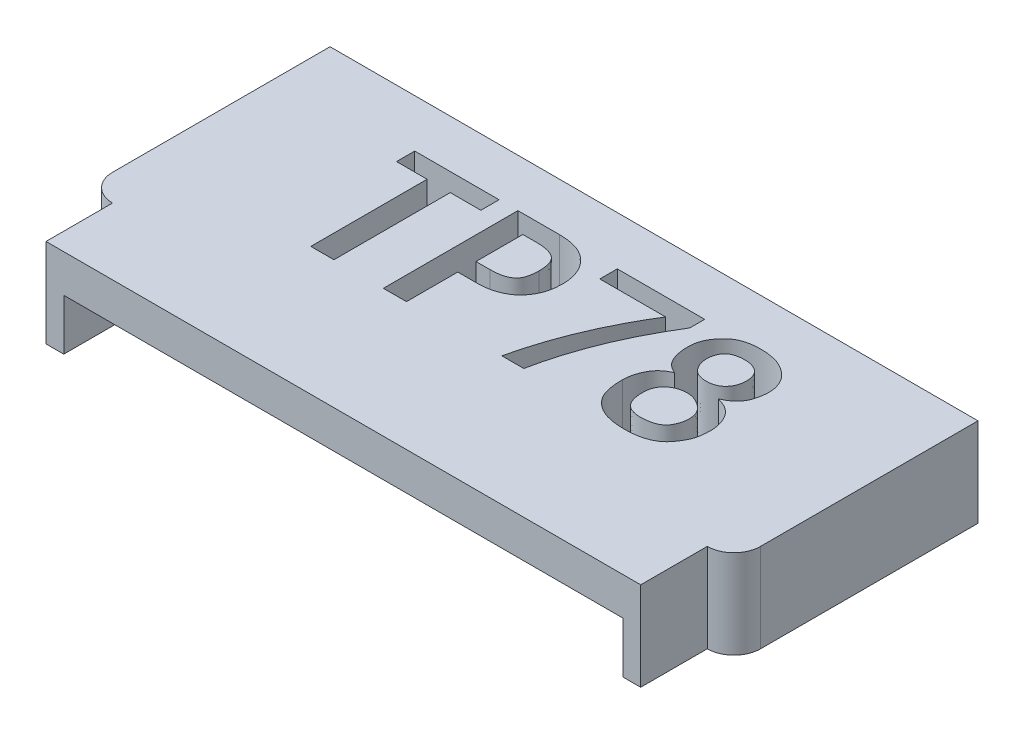
from build123d import *

# Parameters (mm, degrees)
EXTRUDE_1_DEPTH     = 2
SKETCH_2_W          = 13.4
SKETCH_2_H          = 0.85
EXTRUDE_2_DEPTH     = 1.5
SKETCH_4_W          = 0.4
SKETCH_4_H          = 1.5
EXTRUDE_3_DEPTH     = 1.15
CUT_EXTRUDE_2_DEPTH = 1.9


with BuildPart() as part:
    # 草图1 → 凸台-拉伸1 (new body)
    with BuildSketch(Plane(origin=(0, 0, 0), x_dir=(1, 0, 0), z_dir=(0, 1, 0))):
        with BuildLine():
            Line((0, 0), (14.6, 0))
            Line((14.6, 0), (14.6, -4.9))
            ThreePointArc((14.6, -4.9), (14.424264069, -5.324264069), (14, -5.5))
            Line((14, -5.5), (0.6, -5.5))
            ThreePointArc((0.6, -5.5), (0.175735931, -5.324264069), (0, -4.9))
            Line((0, -4.9), (0, 0))
        make_face()
    extrude(amount=EXTRUDE_1_DEPTH)

    # 草图2 → 凸台-拉伸2 (add)
    with BuildSketch(Plane.XY.offset(5.5)):
        with Locations((7.3, 1.575)):
            Rectangle(SKETCH_2_W, SKETCH_2_H)
    extrude(amount=EXTRUDE_2_DEPTH)

    # 草图4 → 凸台-拉伸3 (add)
    with BuildSketch(Plane.XZ.offset(-1.15)):
        with Locations((13.8, 6.25)):
            Rectangle(SKETCH_4_W, SKETCH_4_H)
        with Locations((0.8, 6.25)):
            Rectangle(SKETCH_4_W, SKETCH_4_H)
    extrude(amount=EXTRUDE_3_DEPTH)

    # 草图5 → 切除-拉伸2 (cut)
    with BuildSketch(Plane(origin=(0, 2, 0), x_dir=(1, 0, 0), z_dir=(0, 1, 0))):
        Polygon((4.890749255, -1.492372346), (4.200990709, -1.492372346), (4.200990709, -4.113454824), (3.679767505, -4.113454824), (3.679767505, -1.492372346), (2.990008958, -1.492372346), (2.990008958, -1.081770796), (4.890749255, -1.081770796), align=None)
        with BuildLine():
            add(Edge.make_bspline(
                [(7.250244058, -2.020102706), (7.249588052, -2.054198925), (7.248300741, -2.12110749), (7.235435369, -2.218842293), (7.215685623, -2.311802101), (7.18683198, -2.399386965), (7.150113887, -2.481946077), (7.105912509, -2.559909986), (7.052578704, -2.6325659), (6.991611486, -2.700022576), (6.923466067, -2.761344443), (6.847973696, -2.814568737), (6.765216911, -2.858896104), (6.67571216, -2.895202208), (6.579674756, -2.924025827), (6.476760526, -2.943758576), (6.367328834, -2.956533615), (6.291994599, -2.957790055), (6.253347743, -2.958434616)],
                knots=[0, 0, 0, 0, 0.000102237, 0.000200624, 0.000295202, 0.000386978, 0.000476702, 0.000565888, 0.000655304, 0.000746525, 0.000838229, 0.000929761, 0.001022929, 0.001119237, 0.001219085, 0.00132322, 0.001433237, 0.001549131, 0.001549131, 0.001549131, 0.001549131], degree=3))
            Line((6.253347743, -2.958434616), (5.836239037, -2.958434616))
            Line((5.836239037, -2.958434616), (5.836239037, -4.113454824))
            Line((5.836239037, -4.113454824), (5.315015833, -4.113454824))
            Line((5.315015833, -4.113454824), (5.315015833, -1.081770796))
            Line((5.315015833, -1.081770796), (6.253347743, -1.081770796))
            add(Edge.make_bspline(
                [(6.253347743, -1.081770796), (6.291994529, -1.082415664), (6.367328626, -1.083672703), (6.476761295, -1.0964435), (6.579672089, -1.116191167), (6.675528981, -1.1449048), (6.764910531, -1.181332217), (6.847145559, -1.226391406), (6.922843349, -1.279466128), (6.99094071, -1.340852959), (7.051979576, -1.408258454), (7.105143306, -1.481139333), (7.150246789, -1.558709082), (7.186782006, -1.641497342), (7.215704849, -1.729045512), (7.235364597, -1.821807991), (7.248341807, -1.919308354), (7.249600543, -1.986004845), (7.250244058, -2.020102706)],
                knots=[0, 0, 0, 0, 0.000115893, 0.00022591, 0.000330045, 0.000429893, 0.000525599, 0.000619079, 0.00071061, 0.000802315, 0.000893536, 0.000982952, 0.001072462, 0.001162186, 0.001253962, 0.00134854, 0.001446282, 0.001548518, 0.001548518, 0.001548518, 0.001548518], degree=3))
        make_face()
        with BuildLine():
            add(Edge.make_bspline(
                [(6.729020854, -2.020102706), (6.728799011, -1.995570897), (6.728371926, -1.948343196), (6.720895699, -1.880729094), (6.709963299, -1.819160596), (6.695441479, -1.763282456), (6.675317679, -1.713608058), (6.650512993, -1.670300322), (6.621598057, -1.632972382), (6.587606561, -1.602043947), (6.549275727, -1.575578765), (6.505772746, -1.553916764), (6.458364391, -1.534085644), (6.405785746, -1.518532418), (6.348453702, -1.507162326), (6.286515449, -1.498785023), (6.219816633, -1.493529018), (6.173753603, -1.492767145), (6.149883961, -1.492372346)],
                knots=[0, 0, 0, 0, 7.3557e-05, 0.000141609, 0.000203768, 0.000261068, 0.000314478, 0.000364035, 0.000410378, 0.000455508, 0.000501354, 0.000549665, 0.000601023, 0.000655372, 0.000713821, 0.000776215, 0.000842791, 0.000914397, 0.000914397, 0.000914397, 0.000914397], degree=3))
            Line((6.149883961, -1.492372346), (5.836239037, -1.492372346))
            Line((5.836239037, -1.492372346), (5.836239037, -2.54718235))
            Line((5.836239037, -2.54718235), (6.149883961, -2.54718235))
            add(Edge.make_bspline(
                [(6.149883961, -2.54718235), (6.173752774, -2.546779196), (6.220030457, -2.545997547), (6.286955445, -2.540818086), (6.349094992, -2.532367303), (6.406467583, -2.521097168), (6.45883251, -2.505242598), (6.506451956, -2.486626016), (6.549371551, -2.464384323), (6.587622875, -2.43819574), (6.621593595, -2.407223656), (6.650514292, -2.36990782), (6.675317291, -2.326596539), (6.695441594, -2.276923199), (6.709963264, -2.221044743), (6.72089571, -2.15947634), (6.728371923, -2.09186221), (6.72879901, -2.044634513), (6.729020854, -2.020102706)],
                knots=[0, 0, 0, 0, 7.1605e-05, 0.000138831, 0.000201225, 0.000259674, 0.000314023, 0.000365136, 0.00041287, 0.000458716, 0.000503846, 0.000550189, 0.000599746, 0.000653156, 0.000710456, 0.000772615, 0.000840667, 0.000914224, 0.000914224, 0.000914224, 0.000914224], degree=3))
        make_face(mode=Mode.SUBTRACT)
        with BuildLine():
            add(Edge.make_bspline(
                [(7.96733266, -4.096536218), (7.994709939, -3.983036552), (8.049416674, -3.756235478), (8.150207552, -3.420671891), (8.263507102, -3.088645113), (8.39292442, -2.76106511), (8.53609074, -2.437331358), (8.693992375, -2.117732258), (8.865201772, -1.801302017), (8.990851814, -1.595731625), (9.054027729, -1.492372346)],
                knots=[0, 0, 0, 0, 0.000350207, 0.000699801, 0.00105066, 0.001402416, 0.00175609, 0.00211229, 0.002471613, 0.002834973, 0.002834973, 0.002834973, 0.002834973], degree=3))
            Line((9.054027729, -1.492372346), (7.571046854, -1.492372346))
            Line((7.571046854, -1.492372346), (7.571046854, -1.098689402))
            Line((7.571046854, -1.098689402), (9.540763006, -1.098689402))
            Line((9.540763006, -1.098689402), (9.540763006, -1.435109372))
            add(Edge.make_bspline(
                [(9.540763006, -1.435109372), (9.474977336, -1.544108021), (9.344644648, -1.760053029), (9.167234931, -2.090418056), (9.007047917, -2.421825745), (8.863286436, -2.754255253), (8.737215627, -3.087891067), (8.627551971, -3.422605552), (8.534087215, -3.75810226), (8.486297588, -3.984117326), (8.46252724, -4.096536218)],
                knots=[0, 0, 0, 0, 0.000381891, 0.000756591, 0.00112446, 0.001485885, 0.001842775, 0.002194036, 0.002542288, 0.00288693, 0.00288693, 0.00288693, 0.00288693], degree=3))
            Line((8.46252724, -4.096536218), (7.96733266, -4.096536218))
        make_face()
        with BuildLine():
            add(Edge.make_bspline(
                [(9.792589947, -3.207007979), (9.793760123, -3.17133425), (9.796120333, -3.099381421), (9.818100079, -2.992561355), (9.85244255, -2.886568474), (9.891155444, -2.800205197), (9.929634042, -2.733591889), (9.963142984, -2.686902576), (9.999156921, -2.642637512), (10.040853383, -2.603918613), (10.08519465, -2.567695637), (10.133374147, -2.535363225), (10.185157896, -2.506071528), (10.222101317, -2.490631809), (10.240933002, -2.482761505)],
                knots=[0, 0, 0, 0, 0.000106916, 0.000215645, 0.00032574, 0.000440771, 0.000498805, 0.000556219, 0.000613041, 0.000669653, 0.000726564, 0.000784678, 0.00084352, 0.000904701, 0.000904701, 0.000904701, 0.000904701], degree=3))
            add(Edge.make_bspline(
                [(10.240933002, -2.482761505), (10.209989156, -2.467701115), (10.150710967, -2.438850381), (10.073833329, -2.381100355), (10.011921268, -2.315173085), (9.967352951, -2.239322454), (9.935215425, -2.157648864), (9.911603401, -2.070860588), (9.894182263, -1.979093039), (9.886373188, -1.883842776), (9.885878084, -1.789092675), (9.894846403, -1.698761585), (9.91265948, -1.614919098), (9.940864352, -1.537425216), (9.976851289, -1.464488627), (10.021960193, -1.395444318), (10.073313116, -1.328052777), (10.132049517, -1.26440245), (10.195889355, -1.205929667), (10.265197309, -1.157716591), (10.337645194, -1.119150515), (10.414072206, -1.0913018), (10.493854251, -1.071571316), (10.576712729, -1.057182965), (10.663058779, -1.048776761), (10.751752137, -1.046435381), (10.840362522, -1.049111208), (10.926690887, -1.0559015), (11.009402887, -1.068618691), (11.090253621, -1.085043129), (11.170138404, -1.110262715), (11.251275148, -1.145106962), (11.333143622, -1.192022078), (11.41668815, -1.246523709), (11.495369578, -1.312624141), (11.563430837, -1.391548744), (11.617616502, -1.482749081), (11.651808819, -1.566348241), (11.673012345, -1.637663777), (11.683044266, -1.694431481), (11.688990343, -1.753381922), (11.690121797, -1.814511491), (11.68696972, -1.878042332), (11.678237719, -1.943655437), (11.665000214, -2.011611365), (11.647988044, -2.080985644), (11.62547523, -2.149629813), (11.593997586, -2.214034912), (11.554127183, -2.272939065), (11.508049887, -2.328377147), (11.45285353, -2.377384168), (11.390892429, -2.422346875), (11.321108322, -2.461925654), (11.27079865, -2.483867698), (11.244987189, -2.495125101)],
                knots=[0, 0, 0, 0, 0.000103043, 0.000197397, 0.000286737, 0.000372555, 0.000459557, 0.000549389, 0.000642046, 0.000739371, 0.000835677, 0.000925937, 0.001011198, 0.001092089, 0.001172699, 0.001254647, 0.001339115, 0.001426617, 0.001514161, 0.001598283, 0.001679202, 0.001759704, 0.001841614, 0.001925486, 0.002011796, 0.002101632, 0.002191469, 0.002277661, 0.002361222, 0.002442392, 0.00252492, 0.002612072, 0.002706751, 0.002807637, 0.002911037, 0.003013943, 0.003118732, 0.003227853, 0.003284075, 0.003341636, 0.003400493, 0.003461674, 0.003524877, 0.003591142, 0.003660056, 0.003732496, 0.003805342, 0.00387635, 0.003946736, 0.004018306, 0.004092018, 0.004167512, 0.004247658, 0.004332101, 0.004332101, 0.004332101, 0.004332101], degree=3))
            add(Edge.make_bspline(
                [(11.244987189, -2.495125101), (11.267446972, -2.501032505), (11.311157039, -2.512529189), (11.3734539, -2.535832602), (11.431401785, -2.562052213), (11.48455692, -2.593140405), (11.533485771, -2.627310489), (11.577629464, -2.666108678), (11.616519255, -2.709191335), (11.662642862, -2.771104568), (11.709921091, -2.855941857), (11.750386127, -2.966680942), (11.775516616, -3.085436721), (11.781845037, -3.208953856), (11.776597719, -3.329551691), (11.762539322, -3.441368921), (11.737313852, -3.540919885), (11.701715671, -3.628334046), (11.658705218, -3.705350776), (11.614730252, -3.776617963), (11.567717066, -3.841985342), (11.51740086, -3.902388407), (11.459963526, -3.956986463), (11.392483288, -4.004635611), (11.315364274, -4.046779217), (11.228293799, -4.083377324), (11.13107685, -4.112586045), (11.023335319, -4.132933443), (10.905654772, -4.146015283), (10.78101608, -4.149043714), (10.656270539, -4.145618783), (10.537690352, -4.134230849), (10.428397633, -4.114831186), (10.328119415, -4.087930083), (10.236817863, -4.051772399), (10.15349143, -4.007895794), (10.077270568, -3.95647466), (10.00978627, -3.8964806), (9.950719251, -3.830164452), (9.902231243, -3.757069017), (9.863480625, -3.678637324), (9.835524627, -3.594158535), (9.816928336, -3.504449091), (9.802378425, -3.409990887), (9.793875625, -3.310194462), (9.793025262, -3.2419457), (9.792589947, -3.207007979)],
                knots=[0, 0, 0, 0, 6.963e-05, 0.00013551, 0.000199273, 0.000260211, 0.000319971, 0.000378064, 0.000436105, 0.000493759, 0.000609421, 0.000725949, 0.000846296, 0.000972126, 0.001095872, 0.001208146, 0.001309629, 0.001403035, 0.001490386, 0.001573985, 0.001654168, 0.001731737, 0.001809533, 0.001891153, 0.001978816, 0.00207272, 0.002174002, 0.002282732, 0.002401228, 0.002528828, 0.002656428, 0.002775436, 0.002885845, 0.002989088, 0.00308636, 0.003179797, 0.003271122, 0.003361475, 0.003449992, 0.003536801, 0.003623814, 0.00371168, 0.003802941, 0.003898374, 0.003998292, 0.00410309, 0.00410309, 0.00410309, 0.00410309], degree=3))
        make_face()
        with BuildLine():
            add(Edge.make_bspline(
                [(10.269564489, -3.194644382), (10.269066846, -3.227196447), (10.268108314, -3.289896357), (10.278249837, -3.38054464), (10.299584364, -3.463208345), (10.328263965, -3.538704061), (10.370392205, -3.604533784), (10.4270412, -3.657044079), (10.497160091, -3.6952807), (10.57824471, -3.719950463), (10.667164891, -3.731796465), (10.761245244, -3.73473679), (10.859106412, -3.72548065), (10.942327992, -3.71050444), (11.008123575, -3.69238714), (11.054229304, -3.673773921), (11.096604607, -3.651997712), (11.134742773, -3.625607495), (11.168867246, -3.595499981), (11.198985018, -3.561379739), (11.225219415, -3.523371977), (11.253980098, -3.468128001), (11.281679776, -3.396044148), (11.303135931, -3.307863666), (11.310180418, -3.219429597), (11.305616411, -3.146377999), (11.294634903, -3.089296), (11.281764328, -3.047804638), (11.262882935, -3.008769356), (11.240948798, -2.970229541), (11.212840152, -2.934416074), (11.180459651, -2.899915313), (11.143121349, -2.86762383), (11.088713049, -2.826575036), (11.015297025, -2.784626303), (10.923223554, -2.748059605), (10.827790873, -2.730353473), (10.732106483, -2.730180278), (10.639393625, -2.744147518), (10.55307402, -2.772172647), (10.474963818, -2.813937849), (10.405827159, -2.867847069), (10.347506367, -2.933617356), (10.305654376, -3.011962399), (10.277288418, -3.099748183), (10.272195705, -3.162317267), (10.269564489, -3.194644382)],
                knots=[0, 0, 0, 0, 9.761e-05, 0.00018801, 0.000272603, 0.0003532, 0.000429364, 0.000504875, 0.000582362, 0.000666948, 0.000757685, 0.000850773, 0.000948747, 0.001051997, 0.001104107, 0.001153166, 0.0012009, 0.001246746, 0.001291923, 0.0013371, 0.001382946, 0.001430104, 0.001523635, 0.001613916, 0.001701405, 0.001788798, 0.00183257, 0.001875581, 0.001918666, 0.001962415, 0.002008358, 0.002054851, 0.00210419, 0.002156247, 0.002259155, 0.002356797, 0.002452133, 0.002548441, 0.002642588, 0.002732307, 0.002819349, 0.002906955, 0.002994124, 0.003080904, 0.003171662, 0.003268677, 0.003268677, 0.003268677, 0.003268677], degree=3))
        make_face(mode=Mode.SUBTRACT)
        with BuildLine():
            add(Edge.make_bspline(
                [(10.331382472, -1.848313785), (10.332525424, -1.875998682), (10.334789033, -1.930828411), (10.356200931, -2.010286681), (10.388762861, -2.085823027), (10.427461122, -2.143375626), (10.463854604, -2.18609641), (10.496376653, -2.213549561), (10.532138113, -2.237099158), (10.571847337, -2.25601942), (10.614790721, -2.271067233), (10.661571765, -2.281229969), (10.711850545, -2.287911703), (10.764755015, -2.289294371), (10.817927598, -2.28805272), (10.868846821, -2.280547994), (10.916539618, -2.269552614), (10.961383896, -2.254883009), (11.00227474, -2.234512106), (11.040022662, -2.210037977), (11.07471959, -2.181375187), (11.115775138, -2.137178524), (11.158888366, -2.075423438), (11.194590577, -1.992344765), (11.214059091, -1.902481181), (11.216940703, -1.824354232), (11.211915983, -1.761730569), (11.204329938, -1.717005646), (11.192605291, -1.675510889), (11.176745057, -1.637381882), (11.157550085, -1.602109193), (11.133454198, -1.570547271), (11.106380434, -1.541638687), (11.063677585, -1.508565538), (11.002999879, -1.474387369), (10.919690403, -1.447326949), (10.826065595, -1.436059905), (10.743093403, -1.436877261), (10.675364224, -1.443447708), (10.62702183, -1.451775359), (10.582876678, -1.463468338), (10.542449575, -1.477771183), (10.506138111, -1.495405816), (10.47313875, -1.515279933), (10.444779213, -1.539329345), (10.411964669, -1.574667896), (10.379677916, -1.625722353), (10.350827889, -1.693282507), (10.334820765, -1.768628493), (10.332555446, -1.821129145), (10.331382472, -1.848313785)],
                knots=[0, 0, 0, 0, 8.2897e-05, 0.000164176, 0.000245179, 0.00032874, 0.000371161, 0.000413156, 0.000455931, 0.000499295, 0.000544775, 0.000592135, 0.000642661, 0.000696705, 0.00075075, 0.000802008, 0.000850781, 0.000897492, 0.000943182, 0.000987402, 0.001032226, 0.001077799, 0.001168052, 0.001256656, 0.001347281, 0.001442366, 0.001490028, 0.001535602, 0.001578237, 0.001619082, 0.001659279, 0.001698322, 0.001737904, 0.001777741, 0.001859907, 0.00194551, 0.002038735, 0.00214155, 0.002193867, 0.002242757, 0.00228853, 0.002330726, 0.002371181, 0.002409463, 0.002445955, 0.002482331, 0.002553803, 0.002625833, 0.002701777, 0.002783327, 0.002783327, 0.002783327, 0.002783327], degree=3))
        make_face(mode=Mode.SUBTRACT)
    extrude(amount=-CUT_EXTRUDE_2_DEPTH, mode=Mode.SUBTRACT)


solid = part.part
